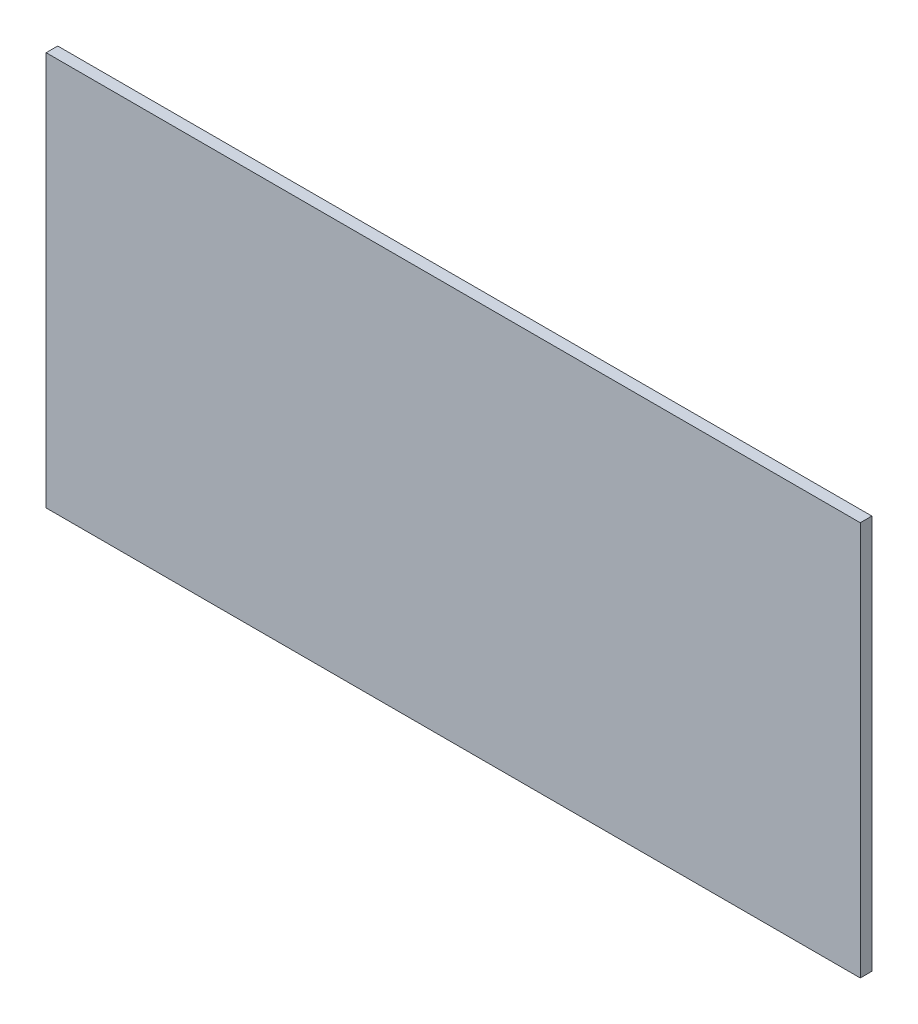
from build123d import *

# Parameters (mm, degrees)
SKETCH1_W           = 111.5
SKETCH1_H           = 54
BOSS_EXTRUDE1_DEPTH = 1.5875


with BuildPart() as part:
    # Sketch1 → Boss-Extrude1 (new body)
    with BuildSketch(Plane.XY):
        with Locations((55.75, 27)):
            Rectangle(SKETCH1_W, SKETCH1_H)
    extrude(amount=BOSS_EXTRUDE1_DEPTH)


solid = part.part
